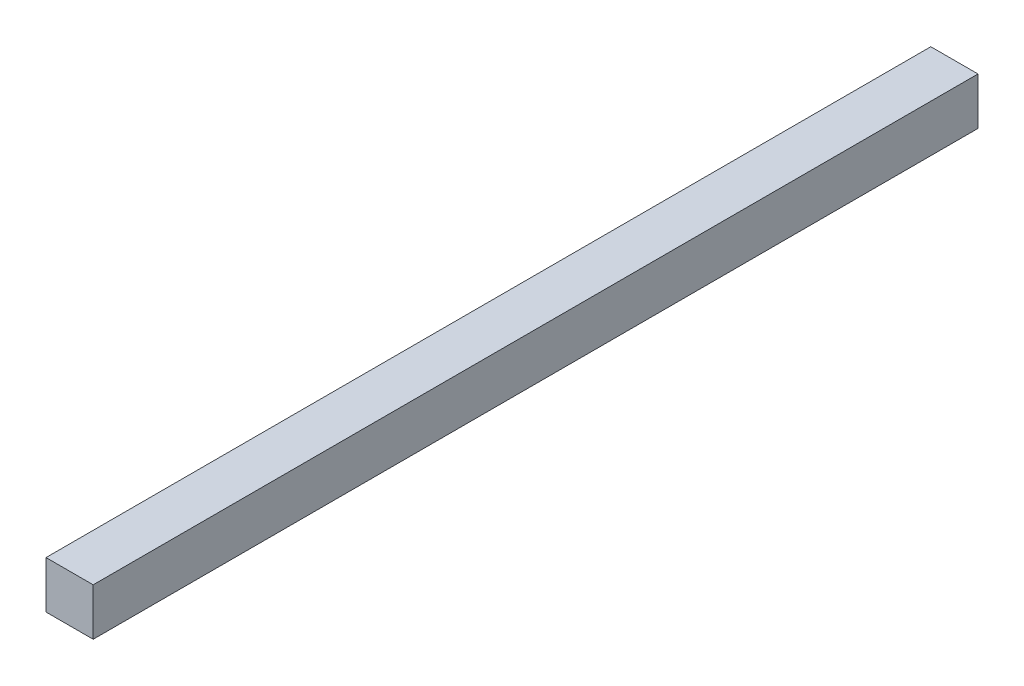
from build123d import *

# Parameters (mm, degrees)
SZKIC1_W                    = 20
SZKIC1_H                    = 20
DODANIE_WYCI_GNI_CIE1_DEPTH = 375


with BuildPart() as part:
    # Szkic1 → Dodanie-wyciągnięcie1 (new body)
    with BuildSketch(Plane.XY):
        with Locations((10, 10)):
            Rectangle(SZKIC1_W, SZKIC1_H)
    extrude(amount=-DODANIE_WYCI_GNI_CIE1_DEPTH)


solid = part.part
